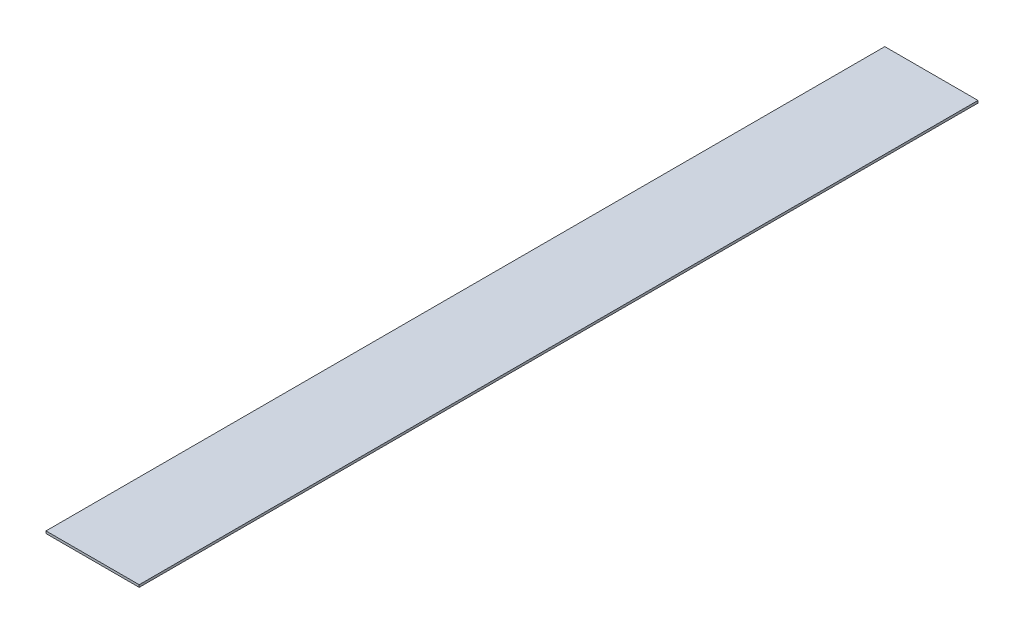
from build123d import *

# Parameters (mm, degrees)
SKETCH1_W           = 50.8
SKETCH1_H           = 457.2
BOSS_EXTRUDE1_DEPTH = 1.27


with BuildPart() as part:
    # Sketch1 → Boss-Extrude1 (new body)
    with BuildSketch(Plane(origin=(0, 0, 0), x_dir=(1, 0, 0), z_dir=(0, 1, 0))):
        Rectangle(SKETCH1_W, SKETCH1_H)
    extrude(amount=BOSS_EXTRUDE1_DEPTH)


solid = part.part
